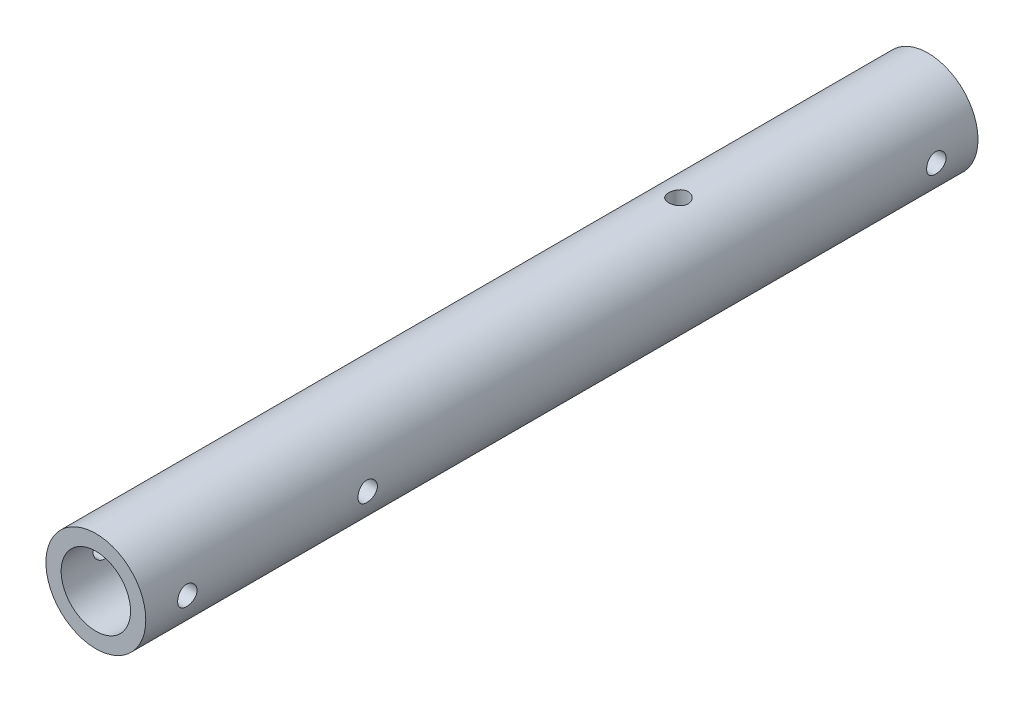
from build123d import *

# Parameters (mm, degrees)
SKETCH_1_R               = 9
SKETCH_1_R_2             = 6.25
EXTRUDE_1_DEPTH          = 150
SKETCH_2_R               = 1.75
CUT_EXTRUDE_1_DEPTH      = 10
CUT_EXTRUDE_1_DEPTH_BACK = 10
SKETCH_3_R               = 1.75
CUT_EXTRUDE_2_DEPTH      = 10.0000001
CUT_EXTRUDE_2_DEPTH_BACK = 10.0000001


with BuildPart() as part:
    # ｽｹｯﾁ1 → ﾎﾞｽ - 押し出し1 (new body)
    with BuildSketch(Plane.XY):
        Circle(SKETCH_1_R)
        Circle(SKETCH_1_R_2, mode=Mode.SUBTRACT)
    extrude(amount=EXTRUDE_1_DEPTH)

    # ｽｹｯﾁ2 → ｶｯﾄ - 押し出し1 (cut, two sides)
    with BuildSketch(Plane(origin=(0, 0, 0), x_dir=(0, 0, -1), z_dir=(1, 0, 0))) as cut_extrude_1_sk:
        with Locations((-7.5, 0)):
            Circle(SKETCH_2_R)
        with Locations((-142.5, 0)):
            Circle(SKETCH_2_R)
        with Locations((-110, 0)):
            Circle(SKETCH_2_R)
    extrude(amount=CUT_EXTRUDE_1_DEPTH, mode=Mode.SUBTRACT)
    extrude(cut_extrude_1_sk.sketch, amount=-CUT_EXTRUDE_1_DEPTH_BACK, mode=Mode.SUBTRACT)

    # ｽｹｯﾁ3 → ｶｯﾄ - 押し出し2 (cut, two sides)
    with BuildSketch(Plane(origin=(0, 0, 0), x_dir=(1, 0, 0), z_dir=(0, 1, 0))) as cut_extrude_2_sk:
        with Locations((0, -45)):
            Circle(SKETCH_3_R)
    extrude(amount=CUT_EXTRUDE_2_DEPTH, mode=Mode.SUBTRACT)
    extrude(cut_extrude_2_sk.sketch, amount=-CUT_EXTRUDE_2_DEPTH_BACK, mode=Mode.SUBTRACT)


solid = part.part
